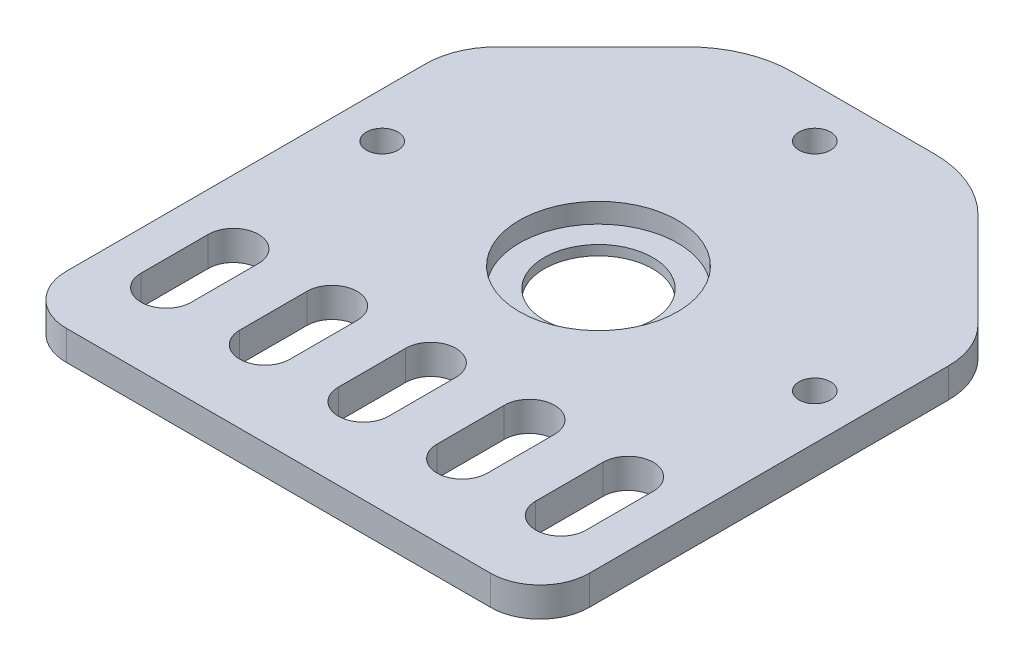
from build123d import *

# Parameters (mm, degrees)
SKETCH1_R           = 1.6
SKETCH1_R_2         = 5.5
BOSS_EXTRUDE1_DEPTH = 3
SKETCH2_R           = 8.025
CUT_EXTRUDE1_DEPTH  = 2


with BuildPart() as part:
    # Sketch1 → Boss-Extrude1 (new body)
    with BuildSketch(Plane(origin=(0, 0, 0), x_dir=(1, 0, 0), z_dir=(0, 1, 0))):
        with BuildLine():
            Line((21.5, -32.43), (-21.5, -32.43))
            ThreePointArc((-21.5, -32.43), (-25.035533906, -30.965533906), (-26.5, -27.43))
            Line((-26.5, -27.43), (-26.5, 8.956951673))
            ThreePointArc((-26.5, 8.956951673), (-25.948126611, 11.731406557), (-24.376524164, 14.083475836))
            Line((-24.376524164, 14.083475836), (-14.728099577, 23.731900423))
            ThreePointArc((-14.728099577, 23.731900423), (-11.263258212, 26.047033407), (-7.176199154, 26.86))
            Line((-7.176199154, 26.86), (7.176199154, 26.86))
            ThreePointArc((7.176199154, 26.86), (11.263258212, 26.047033407), (14.728099577, 23.731900423))
            Line((14.728099577, 23.731900423), (24.376524164, 14.083475836))
            ThreePointArc((24.376524164, 14.083475836), (25.948126611, 11.731406557), (26.5, 8.956951673))
            Line((26.5, 8.956951673), (26.5, -27.43))
            ThreePointArc((26.5, -27.43), (25.035533906, -30.965533906), (21.5, -32.43))
        make_face()
        with Locations((21.920310217, 0)):
            Circle(SKETCH1_R, mode=Mode.SUBTRACT)
        with Locations((-21.920310217, 0)):
            Circle(SKETCH1_R, mode=Mode.SUBTRACT)
        Circle(SKETCH1_R_2, mode=Mode.SUBTRACT)
        with Locations((0, 21.920310217)):
            Circle(SKETCH1_R, mode=Mode.SUBTRACT)
        with BuildLine():
            Line((17.45, -23.81), (17.45, -17))
            ThreePointArc((17.45, -17), (20, -14.45), (22.55, -17))
            Line((22.55, -17), (22.55, -23.81))
            ThreePointArc((22.55, -23.81), (20, -26.36), (17.45, -23.81))
        make_face(mode=Mode.SUBTRACT)
        with BuildLine():
            Line((7.45, -23.81), (7.45, -17))
            ThreePointArc((7.45, -17), (10, -14.45), (12.55, -17))
            Line((12.55, -17), (12.55, -23.81))
            ThreePointArc((12.55, -23.81), (10, -26.36), (7.45, -23.81))
        make_face(mode=Mode.SUBTRACT)
        with BuildLine():
            Line((-2.55, -23.81), (-2.55, -17))
            ThreePointArc((-2.55, -17), (0, -14.45), (2.55, -17))
            Line((2.55, -17), (2.55, -23.81))
            ThreePointArc((2.55, -23.81), (0, -26.36), (-2.55, -23.81))
        make_face(mode=Mode.SUBTRACT)
        with BuildLine():
            Line((-12.55, -23.81), (-12.55, -17))
            ThreePointArc((-12.55, -17), (-10, -14.45), (-7.45, -17))
            Line((-7.45, -17), (-7.45, -23.81))
            ThreePointArc((-7.45, -23.81), (-10, -26.36), (-12.55, -23.81))
        make_face(mode=Mode.SUBTRACT)
        with BuildLine():
            Line((-22.55, -23.81), (-22.55, -17))
            ThreePointArc((-22.55, -17), (-20, -14.45), (-17.45, -17))
            Line((-17.45, -17), (-17.45, -23.81))
            ThreePointArc((-17.45, -23.81), (-20, -26.36), (-22.55, -23.81))
        make_face(mode=Mode.SUBTRACT)
    extrude(amount=BOSS_EXTRUDE1_DEPTH)

    # Sketch2 → Cut-Extrude1 (cut)
    with BuildSketch(Plane(origin=(0, 3, 0), x_dir=(1, 0, 0), z_dir=(0, 1, 0))):
        Circle(SKETCH2_R)
    extrude(amount=-CUT_EXTRUDE1_DEPTH, mode=Mode.SUBTRACT)


solid = part.part
